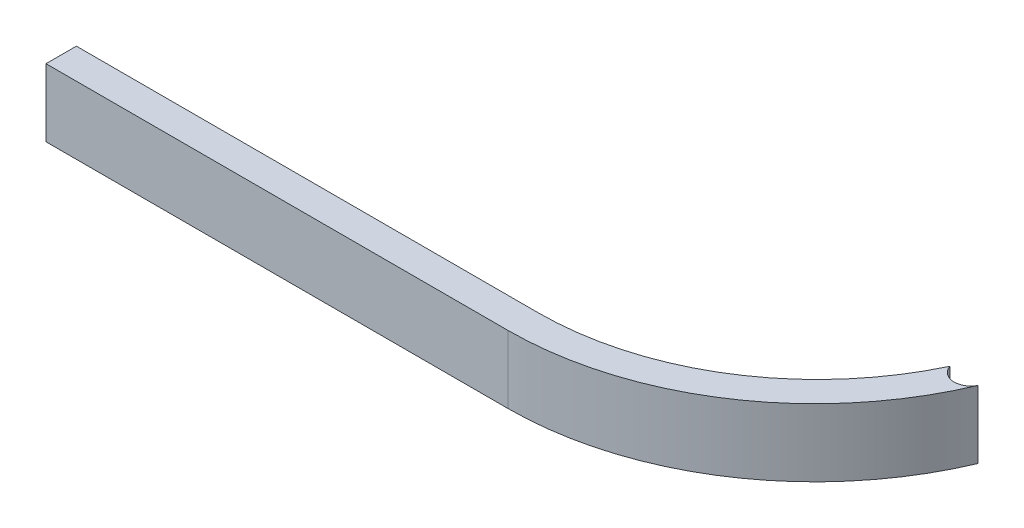
from build123d import *

# Parameters (mm, degrees)
BOSS_EXTRUDE1_DEPTH = 10


with BuildPart() as part:
    # Sketch2 → Boss-Extrude1 (new body)
    with BuildSketch(Plane(origin=(0, 0, 0), x_dir=(1, 0, 0), z_dir=(0, 1, 0))):
        with BuildLine():
            Line((-53.431, -7.07175), (-53.431, -11.56175))
            Line((-53.431, -11.56175), (14.817, -11.56175))
            ThreePointArc((14.817, -11.56175), (39.884287183, -4.010899621), (56.610443192, 16.129108655))
            ThreePointArc((56.610443192, 16.129108655), (54.223509177, 14.808161455), (52.084, 16.50075))
            ThreePointArc((52.084, 16.50075), (36.865197462, -0.683974082), (14.817, -7.07175))
            Line((14.817, -7.07175), (-53.431, -7.07175))
        make_face()
    extrude(amount=BOSS_EXTRUDE1_DEPTH)


solid = part.part
